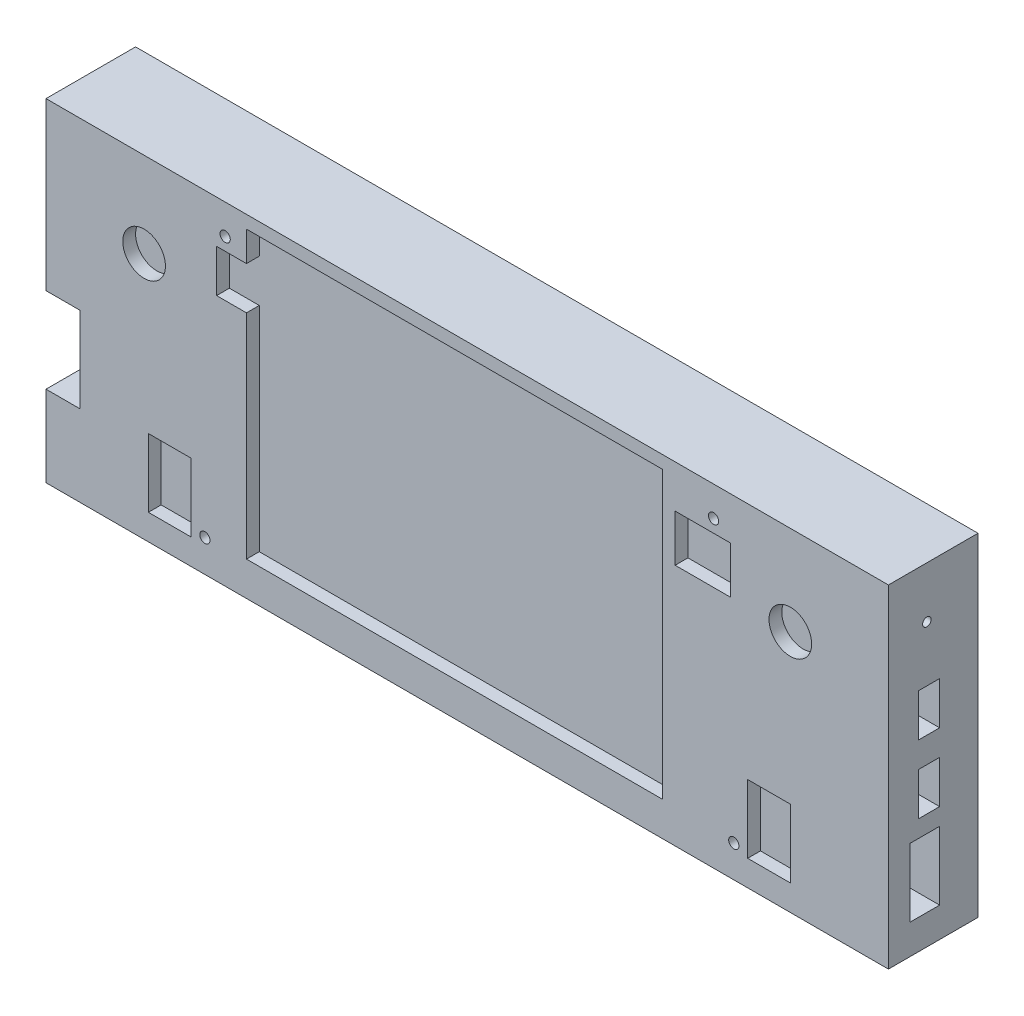
from build123d import *

# Parameters (mm, degrees)
SKETCH1_R           = 1.2
SKETCH1_R_2         = 5
SKETCH1_W           = 13
SKETCH1_H           = 11
SKETCH1_W_2         = 10
SKETCH1_H_2         = 16
BOSS_EXTRUDE2_DEPTH = 3
SKETCH2_W           = 197.5
SKETCH2_H           = 78
BOSS_EXTRUDE3_DEPTH = 18
SKETCH3_W           = 191.5
SKETCH3_H           = 72
CUT_EXTRUDE1_DEPTH  = 1
SKETCH4_W           = 177.5
SKETCH4_H           = 55
CUT_EXTRUDE2_DEPTH  = 1
SKETCH5_W           = 11
SKETCH5_H           = 20
CUT_EXTRUDE3_DEPTH  = 8
SKETCH6_R           = 1
SKETCH6_W           = 7
SKETCH6_H           = 16
SKETCH6_W_2         = 5
SKETCH6_H_2         = 10
CUT_EXTRUDE4_DEPTH  = 10


with BuildPart() as part:
    # Sketch1 → Boss-Extrude2 (new body)
    with BuildSketch(Plane.XY):
        Polygon((0, 0), (197.5, 0), (197.5, 78), (0, 78), (0, 39), (8, 39), (8, 19), (0, 19), align=None)
        with Locations((37.25, 7.5)):
            Circle(SKETCH1_R, mode=Mode.SUBTRACT)
        with Locations((161.25, 7.5)):
            Circle(SKETCH1_R, mode=Mode.SUBTRACT)
        with Locations((156.5, 71)):
            Circle(SKETCH1_R, mode=Mode.SUBTRACT)
        with Locations((42, 71)):
            Circle(SKETCH1_R, mode=Mode.SUBTRACT)
        with Locations((23, 58)):
            Circle(SKETCH1_R_2, mode=Mode.SUBTRACT)
        with Locations((174.5, 57)):
            Circle(SKETCH1_R_2, mode=Mode.SUBTRACT)
        Polygon((47, 75), (47, 68), (40, 68), (40, 58), (47, 58), (47, 8), (144.5, 8), (144.5, 75), align=None, mode=Mode.SUBTRACT)
        with Locations((154, 62.5)):
            Rectangle(SKETCH1_W, SKETCH1_H, mode=Mode.SUBTRACT)
        with Locations((169.5, 14)):
            Rectangle(SKETCH1_W_2, SKETCH1_H_2, mode=Mode.SUBTRACT)
        with Locations((29, 14)):
            Rectangle(SKETCH1_W_2, SKETCH1_H_2, mode=Mode.SUBTRACT)
    extrude(amount=BOSS_EXTRUDE2_DEPTH)

    # Sketch2 → Boss-Extrude3 (add)
    with BuildSketch(Plane(origin=(0, 0, 0), x_dir=(-1, 0, 0), z_dir=(0, 0, -1))):
        with Locations((-98.75, 39)):
            Rectangle(SKETCH2_W, SKETCH2_H)
    extrude(amount=BOSS_EXTRUDE3_DEPTH)

    # Sketch3 → Cut-Extrude1 (cut)
    with BuildSketch(Plane(origin=(0, 0, -18), x_dir=(-1, 0, 0), z_dir=(0, 0, -1))):
        with Locations((-98.75, 39)):
            Rectangle(SKETCH3_W, SKETCH3_H)
    extrude(amount=-CUT_EXTRUDE1_DEPTH, mode=Mode.SUBTRACT)

    # Sketch4 → Cut-Extrude2 (cut)
    with BuildSketch(Plane(origin=(0, 0, -17), x_dir=(-1, 0, 0), z_dir=(0, 0, -1))):
        with Locations((-98.75, 42.5)):
            Rectangle(SKETCH4_W, SKETCH4_H)
    extrude(amount=-CUT_EXTRUDE2_DEPTH, mode=Mode.SUBTRACT)

    # Sketch5 → Cut-Extrude3 (cut)
    with BuildSketch(Plane.ZY):
        with Locations((-2.5, 29)):
            Rectangle(SKETCH5_W, SKETCH5_H)
    extrude(amount=-CUT_EXTRUDE3_DEPTH, mode=Mode.SUBTRACT)

    # Sketch6 → Cut-Extrude4 (cut)
    with BuildSketch(Plane(origin=(197.5, 0, 0), x_dir=(0, 0, -1), z_dir=(1, 0, 0))):
        with Locations((6, 66)):
            Circle(SKETCH6_R)
        with Locations((5.5, 15)):
            Rectangle(SKETCH6_W, SKETCH6_H)
        with Locations((6.5, 32)):
            Rectangle(SKETCH6_W_2, SKETCH6_H_2)
        with Locations((6.5, 48)):
            Rectangle(SKETCH6_W_2, SKETCH6_H_2)
    extrude(amount=-CUT_EXTRUDE4_DEPTH, mode=Mode.SUBTRACT)


solid = part.part
